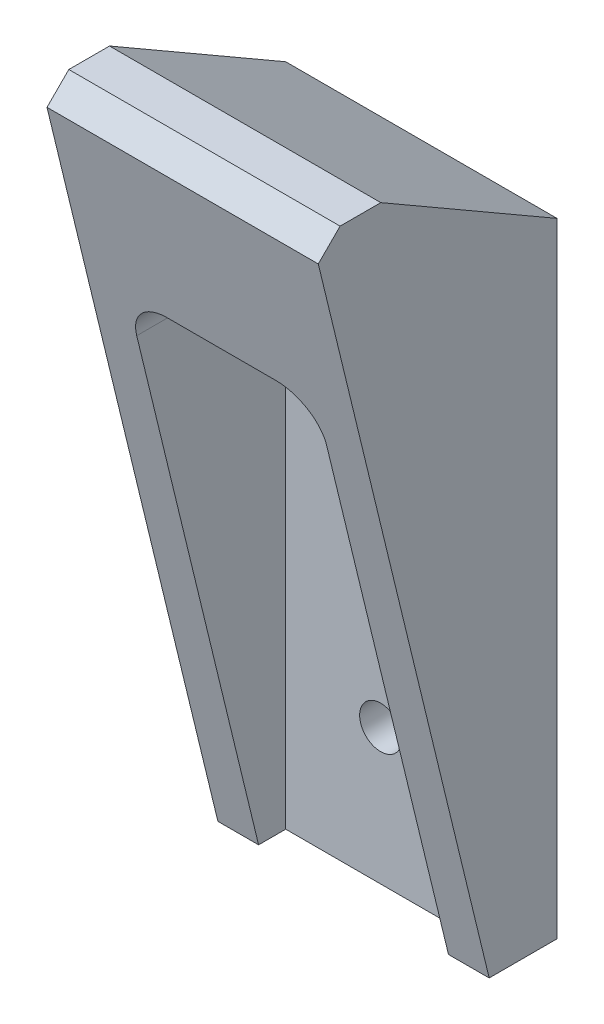
from build123d import *

# Parameters (mm, degrees)
BOSS_EXTRUDE1_DEPTH = 20
CUT_EXTRUDE1_START  = -14.990381
SKETCH4_W           = 14
SKETCH4_H           = 40
CUT_EXTRUDE1_DEPTH  = 11.712434
FILLET1_R           = 3
CHAMFER1_SIZE2      = 2
CHAMFER1_SIZE       = 1.656014526
M3_CLEARANCE_D      = 3.099999896


with BuildPart() as part:
    # Sketch1 → Boss-Extrude1 (new body)
    with BuildSketch(Plane(origin=(0, 0, 0), x_dir=(0, 0, -1), z_dir=(1, 0, 0))):
        Polygon((0, 0), (-5, 0), (-17.990381057, 53.5), (-12.990381057, 53.5), (0, 46), align=None)
    extrude(amount=BOSS_EXTRUDE1_DEPTH)

    # Sketch4 → Cut-Extrude1 (cut)
    with BuildSketch(Plane.XY.offset(17.990381057).offset(CUT_EXTRUDE1_START)):
        with Locations((10, 20)):
            Rectangle(SKETCH4_W, SKETCH4_H)
    extrude(amount=CUT_EXTRUDE1_DEPTH, mode=Mode.SUBTRACT)

    # Fillet1
    fillet1_edges = [part.edges().sort_by_distance(p)[0] for p in [
        (3, 40, 8.856217057),
        (17, 40, 8.856217057),
    ]]
    fillet(fillet1_edges, radius=FILLET1_R)

    # Chamfer1
    chamfer1_edges = [part.edges().sort_by_distance(p)[0] for p in [
        (10, 53.5, 17.990381057),
    ]]
    chamfer(chamfer1_edges, length=CHAMFER1_SIZE, length2=CHAMFER1_SIZE2)

    # M3 Clearance (through all)
    with Locations(Plane(origin=(10, 30, 3), x_dir=(1, 0, 0), z_dir=(0, 0, 1))):
        with Locations((0, 0), (0, -20)):
            Hole(M3_CLEARANCE_D / 2)


solid = part.part
